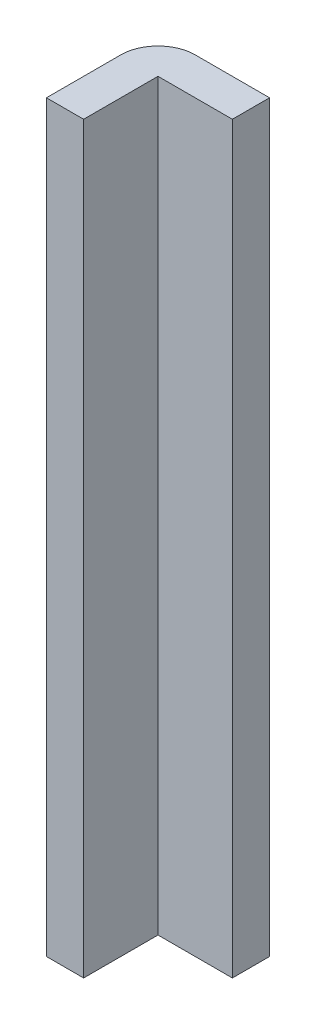
from build123d import *

# Parameters (mm, degrees)
BOSS_EXTRUDE1_DEPTH = 40
FILLET1_R           = 2


with BuildPart() as part:
    # Sketch1 → Boss-Extrude1 (new body)
    with BuildSketch(Plane(origin=(0, 0, 0), x_dir=(1, 0, 0), z_dir=(0, 1, 0))):
        Polygon((0, 0), (-2, 0), (-2, 6), (4, 6), (4, 4), (0, 4), (0, 0.889632107), align=None)
    extrude(amount=BOSS_EXTRUDE1_DEPTH)

    # Fillet1
    fillet1_edges = [part.edges().sort_by_distance(p)[0] for p in [
        (-2, 20, -6),
    ]]
    fillet(fillet1_edges, radius=FILLET1_R)


solid = part.part
